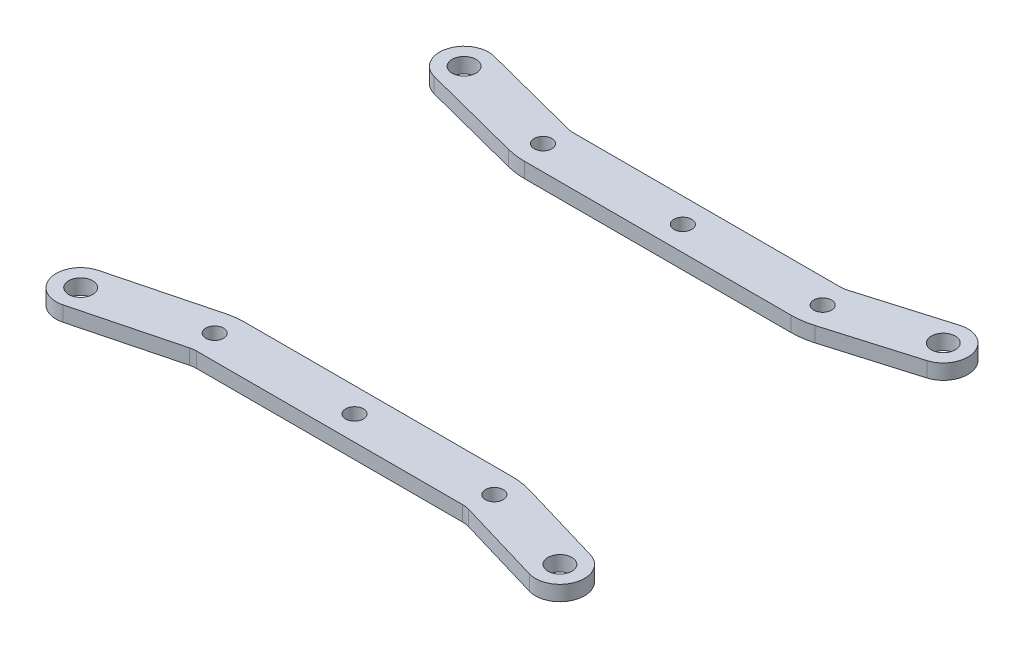
from build123d import *

# Parameters (mm, degrees)
SKETCH3_R           = 2.35
SKETCH3_R_2         = 3.175
BOSS_EXTRUDE1_DEPTH = 4


with BuildPart() as part:
    # Sketch3 → Boss-Extrude1 (new body)
    with BuildSketch(Plane(origin=(0, 0, 0), x_dir=(1, 0, 0), z_dir=(0, 1, 0))):
        with BuildLine():
            Line((-1.62757842, 95.307068371), (24.996187397, 88.421205113))
            ThreePointArc((24.996187397, 88.421205113), (27.417876161, 87.955924676), (29.878922656, 87.8))
            Line((29.878922656, 87.8), (100.442332088, 87.8))
            ThreePointArc((100.442332088, 87.8), (103.237177873, 88.001325511), (105.97431353, 88.601144919))
            Line((105.97431353, 88.601144919), (128.843993814, 95.367048306))
            ThreePointArc((128.843993814, 95.367048306), (133.232951694, 103.443993814), (125.156006186, 107.832951694))
            Line((125.156006186, 107.832951694), (102.286325902, 101.067048306))
            ThreePointArc((102.286325902, 101.067048306), (101.373947349, 100.867108504), (100.442332088, 100.8))
            Line((100.442332088, 100.8), (29.878922656, 100.8))
            ThreePointArc((29.878922656, 100.8), (29.058573824, 100.851974892), (28.251344236, 101.007068371))
            Line((28.251344236, 101.007068371), (1.62757842, 107.892931629))
            ThreePointArc((1.62757842, 107.892931629), (-6.292931629, 103.22757842), (-1.62757842, 95.307068371))
        make_face()
        with Locations((28.225, 94.3)):
            Circle(SKETCH3_R, mode=Mode.SUBTRACT)
        with Locations((65.275, 94.3)):
            Circle(SKETCH3_R, mode=Mode.SUBTRACT)
        with Locations((102.325, 94.3)):
            Circle(SKETCH3_R, mode=Mode.SUBTRACT)
        with Locations((127, 101.6)):
            Circle(SKETCH3_R_2, mode=Mode.SUBTRACT)
        with Locations((0, 101.6)):
            Circle(SKETCH3_R_2, mode=Mode.SUBTRACT)
    extrude(amount=BOSS_EXTRUDE1_DEPTH)


with BuildPart() as body_2:
    # Mirror3: mirrored copy
    add(part.part.mirror(Plane.XY.offset(-50.8)))


solid = Compound([part.part, body_2.part])
